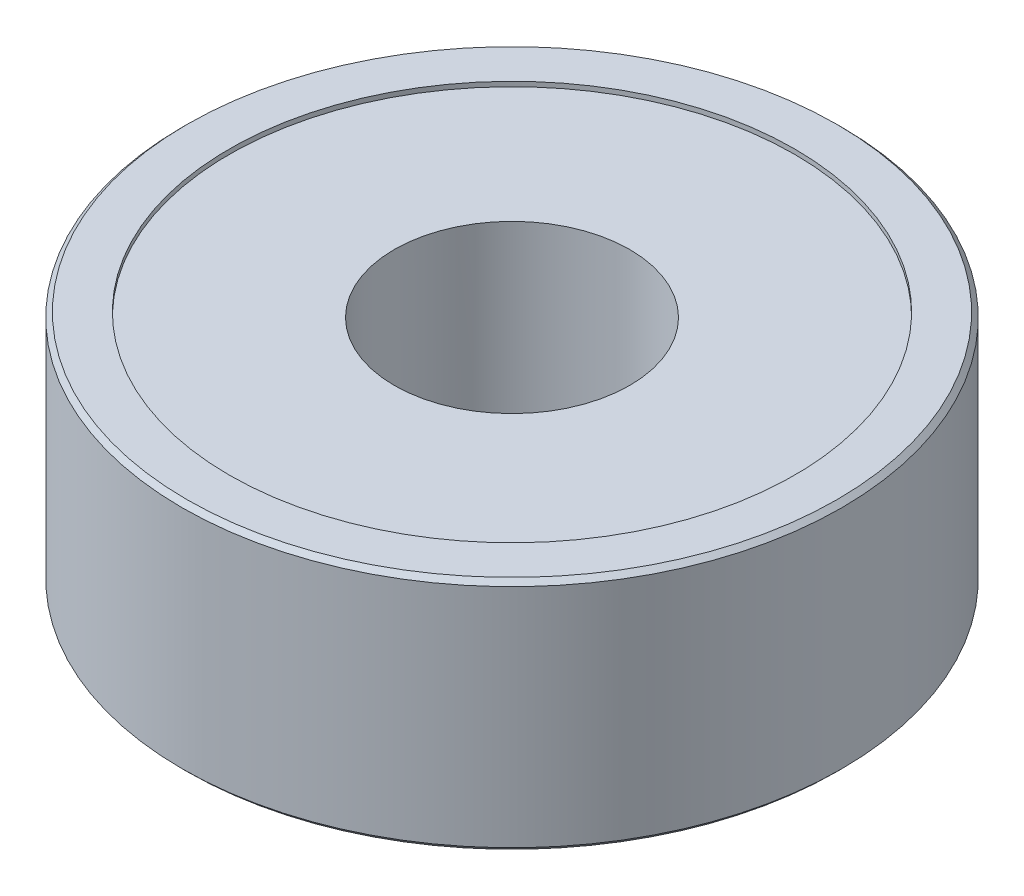
from build123d import *

# Parameters (mm, degrees)
SKETCH1_R           = 7
SKETCH1_R_2         = 2.5
BOSS_EXTRUDE1_DEPTH = 5
SKETCH2_R           = 6
CUT_EXTRUDE1_DEPTH  = 0.1
SKETCH3_R           = 6
CUT_EXTRUDE2_DEPTH  = 0.1
CHAMFER1_SIZE       = 0.1


with BuildPart() as part:
    # Sketch1 → Boss-Extrude1 (new body)
    with BuildSketch(Plane(origin=(0, 0, 0), x_dir=(1, 0, 0), z_dir=(0, 1, 0))):
        Circle(SKETCH1_R)
        Circle(SKETCH1_R_2, mode=Mode.SUBTRACT)
    extrude(amount=BOSS_EXTRUDE1_DEPTH)

    # Sketch2 → Cut-Extrude1 (cut)
    with BuildSketch(Plane(origin=(0, 5, 0), x_dir=(1, 0, 0), z_dir=(0, 1, 0))):
        Circle(SKETCH2_R)
    extrude(amount=-CUT_EXTRUDE1_DEPTH, mode=Mode.SUBTRACT)

    # Sketch3 → Cut-Extrude2 (cut)
    with BuildSketch(Plane.XZ):
        Circle(SKETCH3_R)
    extrude(amount=-CUT_EXTRUDE2_DEPTH, mode=Mode.SUBTRACT)

    # Chamfer1
    chamfer1_edges = [part.edges().sort_by_distance(p)[0] for p in [
        (-7, 0, 0),
        (-7, 5, 0),
    ]]
    chamfer(chamfer1_edges, length=CHAMFER1_SIZE)


solid = part.part
